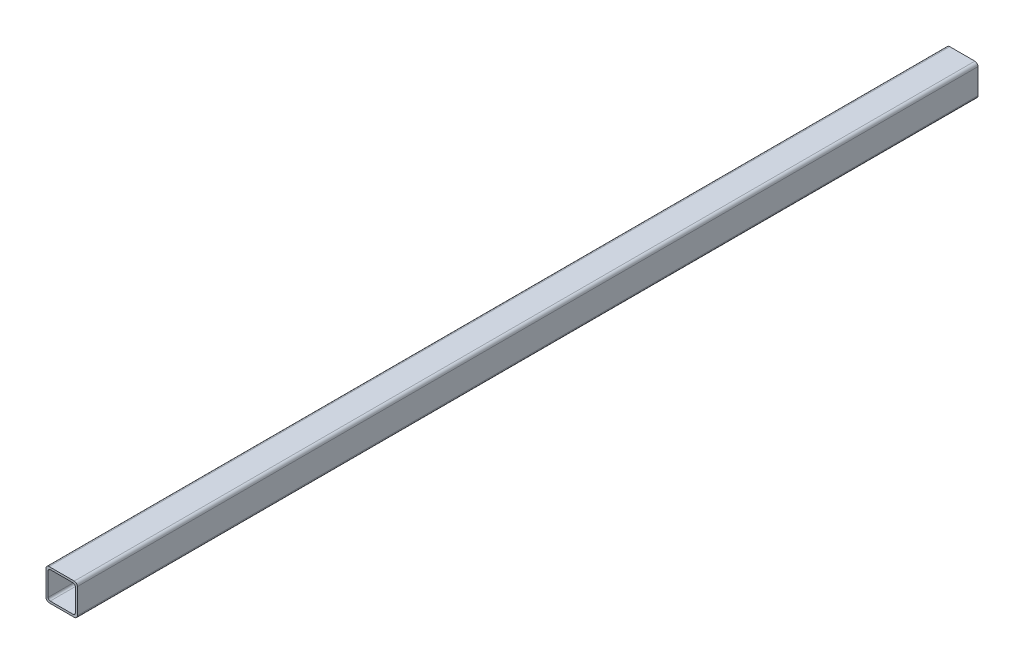
from build123d import *

# Parameters (mm, degrees)
EXTRUDE_1_DEPTH = 430


with BuildPart() as part:
    # Эскиз1 → Бобышка-Вытянуть1 (new body)
    with BuildSketch(Plane.XY):
        with BuildLine():
            Line((-27, 0), (-3, 0))
            ThreePointArc((-3, 0), (-0.878679656, -0.878679656), (0, -3))
            Line((0, -3), (0, -27))
            ThreePointArc((0, -27), (-0.878679656, -29.121320344), (-3, -30))
            Line((-3, -30), (-27, -30))
            ThreePointArc((-27, -30), (-29.121320344, -29.121320344), (-30, -27))
            Line((-30, -27), (-30, -3))
            ThreePointArc((-30, -3), (-29.121320344, -0.878679656), (-27, 0))
        make_face()
        with BuildLine():
            Line((-26, -2), (-4, -2))
            ThreePointArc((-4, -2), (-2.585786438, -2.585786438), (-2, -4))
            Line((-2, -4), (-2, -26))
            ThreePointArc((-2, -26), (-2.585786438, -27.414213562), (-4, -28))
            Line((-4, -28), (-26, -28))
            ThreePointArc((-26, -28), (-27.414213562, -27.414213562), (-28, -26))
            Line((-28, -26), (-28, -4))
            ThreePointArc((-28, -4), (-27.414213562, -2.585786438), (-26, -2))
        make_face(mode=Mode.SUBTRACT)
    extrude(amount=EXTRUDE_1_DEPTH)

    # Зеркальное отражение1: part across plane


with BuildPart() as part_1:
    add(part.part)
    add(part.part.mirror(Plane(origin=(-27, -27, 0), x_dir=(1, 0, 0), z_dir=(0, 0, 1))))


solid = part_1.part
